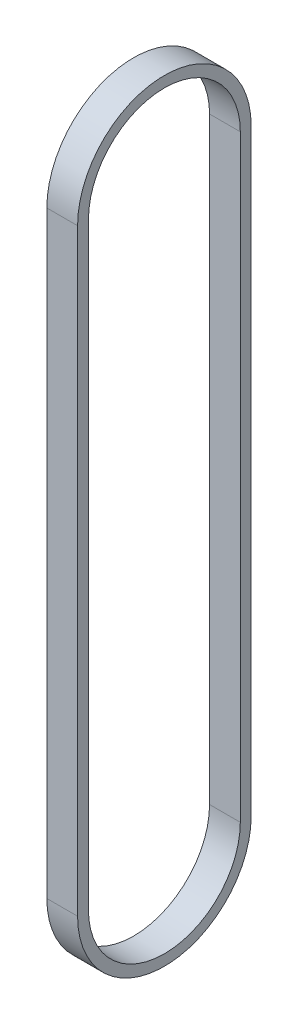
from build123d import *

# Parameters (mm, degrees)
BOSS_EXTRUDE1_DEPTH = 9


with BuildPart() as part:
    # Sketch1 → Boss-Extrude1 (new body)
    with BuildSketch(Plane(origin=(0, 0, 0), x_dir=(0, 0, -1), z_dir=(1, 0, 0))):
        with BuildLine():
            Line((-25.4, 0), (-25.4, 175.02378))
            ThreePointArc((-25.4, 175.02378), (0, 200.42378), (25.4, 175.02378))
            Line((25.4, 175.02378), (25.4, 0))
            ThreePointArc((25.4, 0), (0, -25.4), (-25.4, 0))
        make_face()
        with BuildLine():
            Line((22.225, 175.02378), (22.225, 0))
            ThreePointArc((22.225, 0), (0, -22.225), (-22.225, 0))
            Line((-22.225, 0), (-22.225, 175.02378))
            ThreePointArc((-22.225, 175.02378), (0, 197.24878), (22.225, 175.02378))
        make_face(mode=Mode.SUBTRACT)
    extrude(amount=BOSS_EXTRUDE1_DEPTH)


solid = part.part
